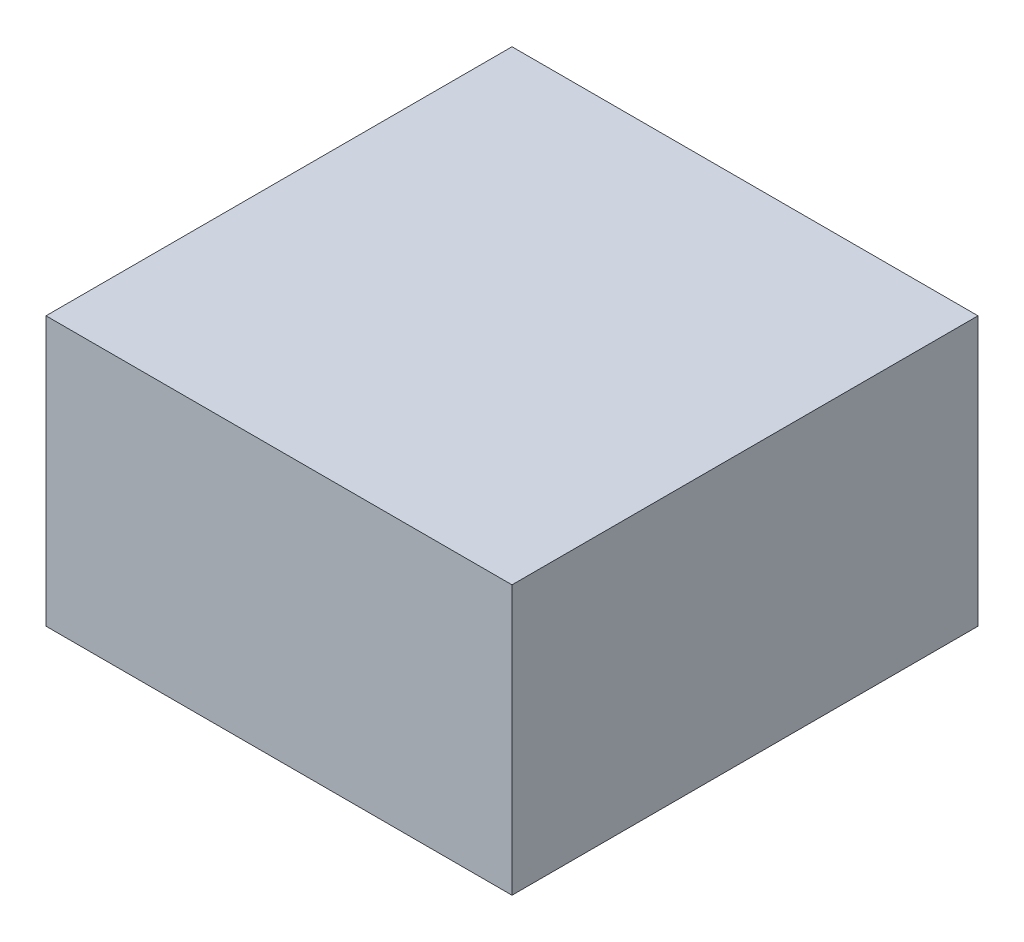
from build123d import *

# Parameters (mm, degrees)
SKETCH1_W           = 99.06
SKETCH1_H           = 99.06
BOSS_EXTRUDE1_DEPTH = 57.15


with BuildPart() as part:
    # Sketch1 → Boss-Extrude1 (new body)
    with BuildSketch(Plane(origin=(0, 0, 0), x_dir=(1, 0, 0), z_dir=(0, 1, 0))):
        with Locations((49.53, 49.53)):
            Rectangle(SKETCH1_W, SKETCH1_H)
    extrude(amount=BOSS_EXTRUDE1_DEPTH)


solid = part.part
